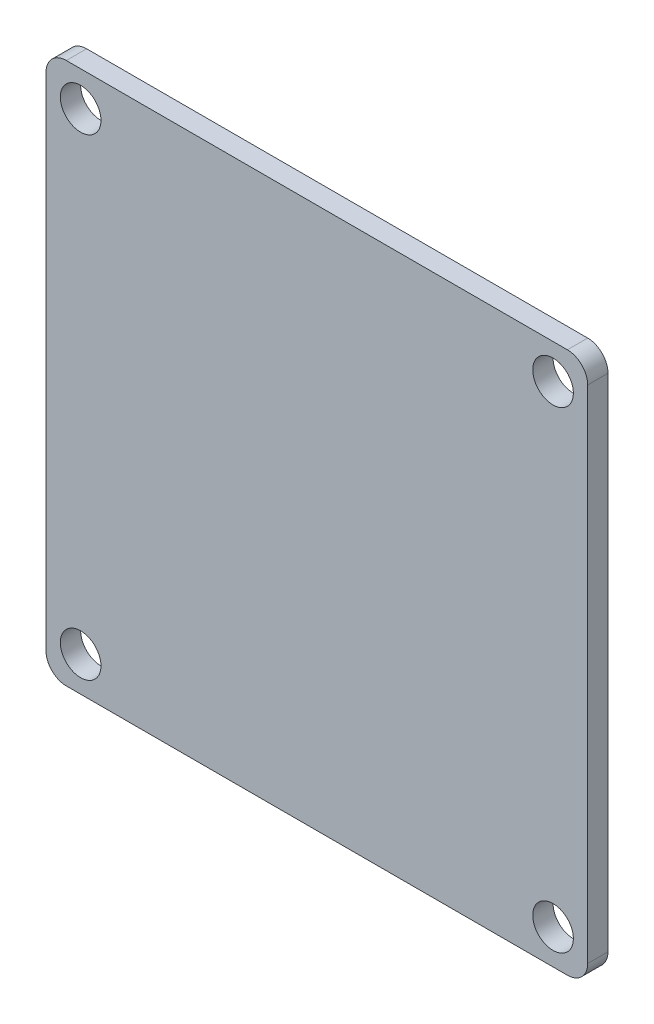
from build123d import *

# Parameters (mm, degrees)
SKETCH_1_R      = 1.5
EXTRUDE_1_DEPTH = 1.5


with BuildPart() as part:
    # 草图1 → 凸台-拉伸1 (new body)
    with BuildSketch(Plane.XY):
        with BuildLine():
            Line((-18.5, -20), (18.5, -20))
            ThreePointArc((18.5, -20), (19.560660172, -19.560660172), (20, -18.5))
            Line((20, -18.5), (20, 18.5))
            ThreePointArc((20, 18.5), (19.560660172, 19.560660172), (18.5, 20))
            Line((18.5, 20), (-18.5, 20))
            ThreePointArc((-18.5, 20), (-19.560660172, 19.560660172), (-20, 18.5))
            Line((-20, 18.5), (-20, -18.5))
            ThreePointArc((-20, -18.5), (-19.560660172, -19.560660172), (-18.5, -20))
        make_face()
        with Locations((-17.442431276, 17.442431276)):
            Circle(SKETCH_1_R, mode=Mode.SUBTRACT)
        with Locations((17.442431276, 17.442431276)):
            Circle(SKETCH_1_R, mode=Mode.SUBTRACT)
        with Locations((17.442431276, -17.442431276)):
            Circle(SKETCH_1_R, mode=Mode.SUBTRACT)
        with Locations((-17.442431276, -17.442431276)):
            Circle(SKETCH_1_R, mode=Mode.SUBTRACT)
    extrude(amount=EXTRUDE_1_DEPTH)


solid = part.part
